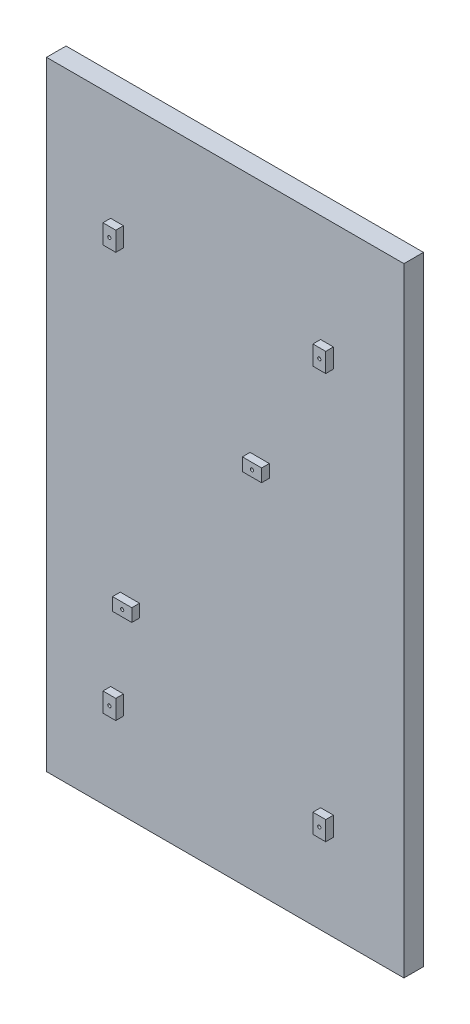
from build123d import *

# Parameters (mm, degrees)
SKETCH1_W           = 111.5
SKETCH1_H           = 193
BOSS_EXTRUDE1_DEPTH = 6.1
SKETCH2_W           = 4
SKETCH2_H           = 6
SKETCH2_R           = 0.5
SKETCH2_W_2         = 6
SKETCH2_H_2         = 4
BOSS_EXTRUDE2_DEPTH = 2.4


with BuildPart() as part:
    # Sketch1 → Boss-Extrude1 (new body)
    with BuildSketch(Plane.XY):
        with Locations((55.75, 96.5)):
            Rectangle(SKETCH1_W, SKETCH1_H)
    extrude(amount=BOSS_EXTRUDE1_DEPTH)

    # Sketch2 → Boss-Extrude2 (add)
    with BuildSketch(Plane.XY.offset(6.1)):
        with Locations((22, 156.5)):
            Rectangle(SKETCH2_W, SKETCH2_H)
        with Locations((22, 156.5)):
            Circle(SKETCH2_R, mode=Mode.SUBTRACT)
        Polygon((87.5, 33), (85.5, 33), (85.5, 27), (89.5, 27), (89.5, 33), align=None)
        with Locations((87.5, 30)):
            Circle(SKETCH2_R, mode=Mode.SUBTRACT)
        with Locations((22, 30)):
            Rectangle(SKETCH2_W, SKETCH2_H)
        with Locations((22, 30)):
            Circle(SKETCH2_R, mode=Mode.SUBTRACT)
        with Locations((87.5, 156.5)):
            Rectangle(SKETCH2_W, SKETCH2_H)
        with Locations((87.5, 156.5)):
            Circle(SKETCH2_R, mode=Mode.SUBTRACT)
        with Locations((26, 58)):
            Rectangle(SKETCH2_W_2, SKETCH2_H_2)
        with Locations((26, 58)):
            Circle(SKETCH2_R, mode=Mode.SUBTRACT)
        with Locations((66.5, 116)):
            Rectangle(SKETCH2_W_2, SKETCH2_H_2)
        with Locations((66.5, 116)):
            Circle(SKETCH2_R, mode=Mode.SUBTRACT)
    extrude(amount=BOSS_EXTRUDE2_DEPTH)


solid = part.part
